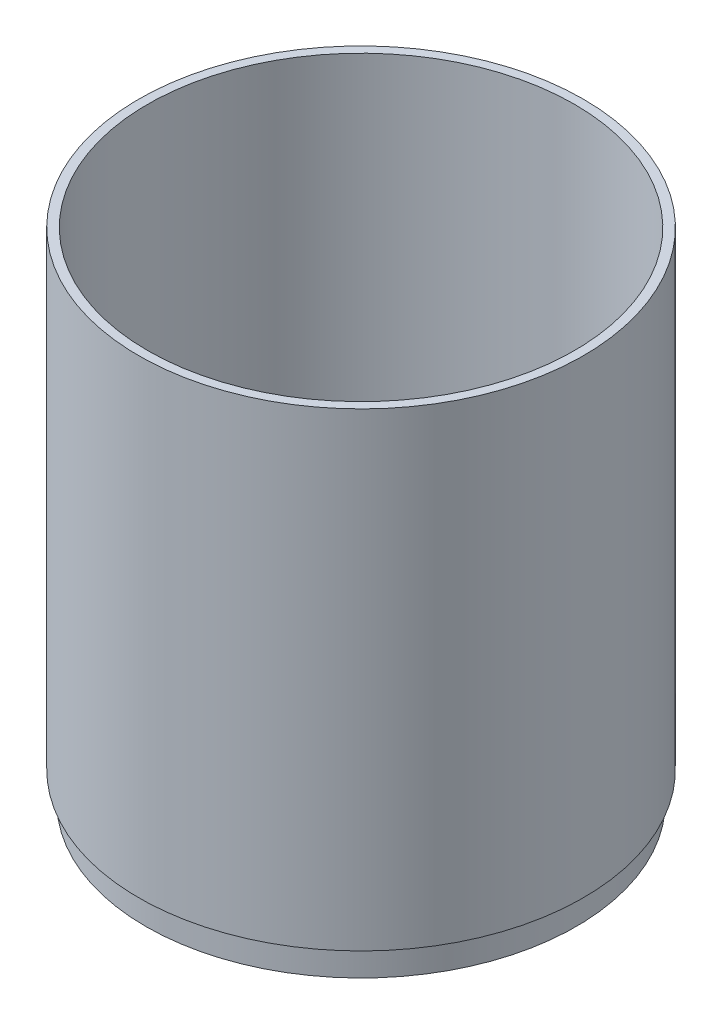
from build123d import *

# Parameters (mm, degrees)
CUT_EXTRUDE1_DEPTH = 10


with BuildPart() as part:
    # Sketch1 → Revolve1 (revolve)
    with BuildSketch(Plane.XY):
        Polygon((60.5, 0), (15, 0), (15, 4), (58.5, 4), (58.5, 10), (60, 10), (60, 140), (62.5, 140), (62.5, 8), (60.5, 8), align=None)
    revolve(axis=Axis((0, 0, 0), (0, 1, 0)))

    # Sketch2 → Cut-Extrude1 (cut)
    with BuildSketch(Plane(origin=(0, 4, 0), x_dir=(1, 0, 0), z_dir=(0, 1, 0))):
        with BuildLine():
            ThreePointArc((19.595917942, -4), (14.142135624, -14.142135624), (4, -19.595917942))
            Line((4, -19.595917942), (4, -58.36308765))
            ThreePointArc((4, -58.36308765), (41.365746699, -41.365746699), (58.36308765, -4))
            Line((58.36308765, -4), (19.595917942, -4))
        make_face()
        with BuildLine():
            Line((22.386980793, 54.046952652), (7.653668647, 18.47759065))
            ThreePointArc((7.653668647, 18.47759065), (15.428387799, 12.726541161), (19.595917942, 4))
            Line((19.595917942, 4), (58.36308765, 4))
            ThreePointArc((58.36308765, 4), (47.500713214, 34.145750016), (22.386980793, 54.046952652))
        make_face()
        with BuildLine():
            ThreePointArc((-19.595917942, 4), (-15.428387799, 12.726541161), (-7.653668647, 18.47759065))
            Line((-7.653668647, 18.47759065), (-22.386980793, 54.046952652))
            ThreePointArc((-22.386980793, 54.046952652), (-47.500713214, 34.145750016), (-58.36308765, 4))
            Line((-58.36308765, 4), (-19.595917942, 4))
        make_face()
        with BuildLine():
            Line((-4, -58.36308765), (-4, -19.595917942))
            ThreePointArc((-4, -19.595917942), (-14.142135624, -14.142135624), (-19.595917942, -4))
            Line((-19.595917942, -4), (-58.36308765, -4))
            ThreePointArc((-58.36308765, -4), (-41.365746699, -41.365746699), (-4, -58.36308765))
        make_face()
    extrude(amount=-CUT_EXTRUDE1_DEPTH, mode=Mode.SUBTRACT)


solid = part.part
